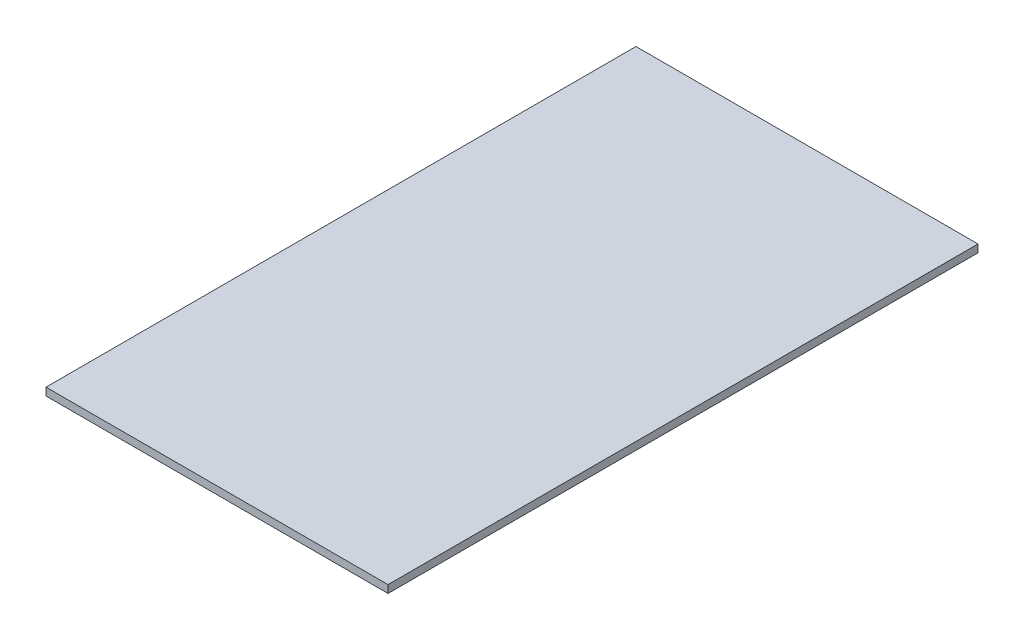
from build123d import *

# Parameters (mm, degrees)
SKETCH1_W           = 80
SKETCH1_H           = 138
BOSS_EXTRUDE1_DEPTH = 1.8


with BuildPart() as part:
    # Sketch1 → Boss-Extrude1 (new body)
    with BuildSketch(Plane(origin=(0, 0, 0), x_dir=(1, 0, 0), z_dir=(0, 1, 0))):
        with Locations((40, 69)):
            Rectangle(SKETCH1_W, SKETCH1_H)
    extrude(amount=BOSS_EXTRUDE1_DEPTH)


solid = part.part
